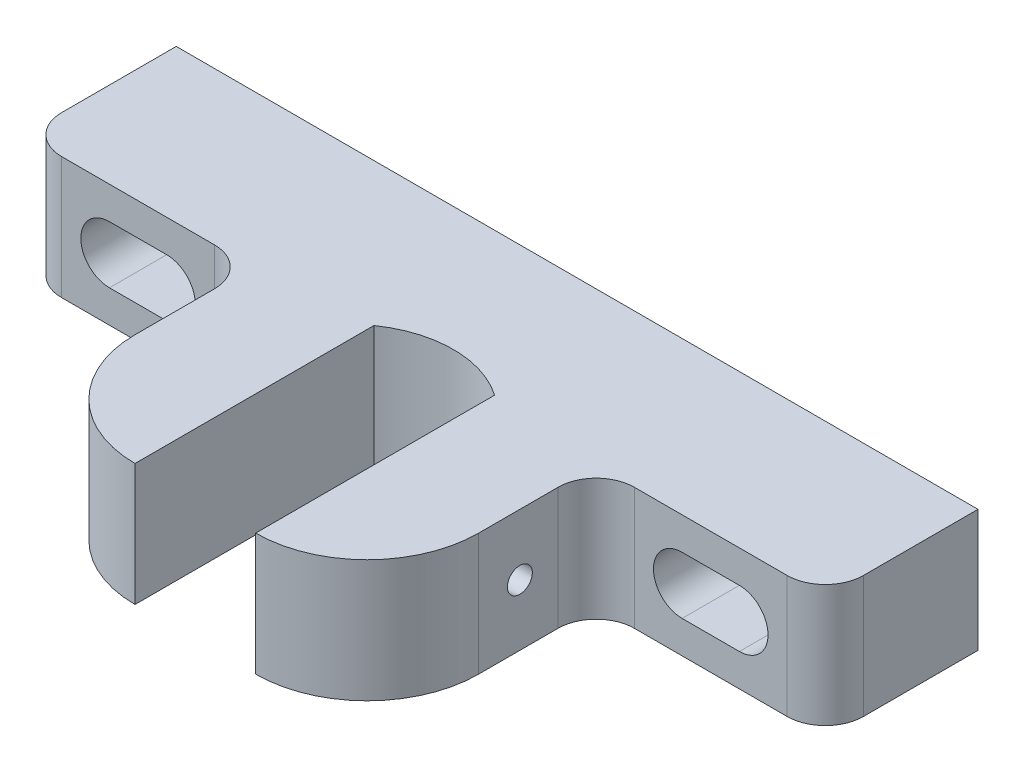
from build123d import *

# Parameters (mm, degrees)
SKETCH1_W          = 133.35
SKETCH1_H          = 20.32
EXTRUDE1_DEPTH     = 63.5
CUT_EXTRUDE1_DEPTH = 21.32
FILLET1_R          = 6.35
CUT_EXTRUDE2_DEPTH = 64.5
SKETCH6_R          = 2.07645
CUT_EXTRUDE5_DEPTH = 67.675


with BuildPart() as part:
    # Sketch1 → Extrude1 (new body)
    with BuildSketch(Plane.XY):
        with Locations((0, 14.12875)):
            Rectangle(SKETCH1_W, SKETCH1_H)
    extrude(amount=EXTRUDE1_DEPTH)

    # Sketch2 → Cut-Extrude1 (cut, through all)
    with BuildSketch(Plane.XZ.offset(-3.96875)):
        with BuildLine():
            Line((-10.033, 23.761628021), (-10.033, 63.5))
            ThreePointArc((-10.033, 63.5), (-23.144173937, 58.069173937), (-28.575, 44.958))
            Line((-28.575, 44.958), (-28.575, 31.75))
            ThreePointArc((-28.575, 31.75), (-30.434871939, 27.259871939), (-34.925, 25.4))
            Line((-34.925, 25.4), (-66.675, 25.4))
            Line((-66.675, 25.4), (-66.675, 63.5))
            Line((-66.675, 63.5), (-66.675, 81.695932909))
            Line((-66.675, 81.695932909), (66.675, 81.695932909))
            Line((66.675, 81.695932909), (66.675, 63.5))
            Line((66.675, 63.5), (66.675, 25.4))
            Line((66.675, 25.4), (34.925, 25.4))
            ThreePointArc((34.925, 25.4), (30.434871939, 27.259871939), (28.575, 31.75))
            Line((28.575, 31.75), (28.575, 44.958))
            ThreePointArc((28.575, 44.958), (23.144173937, 58.069173937), (10.033, 63.5))
            Line((10.033, 63.5), (10.033, 23.761628021))
            ThreePointArc((10.033, 23.761628021), (0, 20.6), (-10.033, 23.761628021))
        make_face()
    extrude(amount=-CUT_EXTRUDE1_DEPTH, mode=Mode.SUBTRACT)

    # Fillet1
    fillet1_edges = [part.edges().sort_by_distance(p)[0] for p in [
        (-66.675, 14.12875, 25.4),
        (66.675, 14.12875, 25.4),
    ]]
    fillet(fillet1_edges, radius=FILLET1_R)

    # Sketch3 → Cut-Extrude2 (cut, through all)
    with BuildSketch(Plane(origin=(0, 0, 0), x_dir=(-1, 0, 0), z_dir=(0, 0, -1))):
        with BuildLine():
            Line((-52.3875, 18.89125), (-42.8625, 18.89125))
            ThreePointArc((-42.8625, 18.89125), (-38.1, 14.12875), (-42.8625, 9.36625))
            Line((-42.8625, 9.36625), (-52.3875, 9.36625))
            ThreePointArc((-52.3875, 9.36625), (-57.15, 14.12875), (-52.3875, 18.89125))
        make_face()
        with BuildLine():
            Line((52.3875, 9.36625), (42.8625, 9.36625))
            ThreePointArc((42.8625, 9.36625), (38.1, 14.12875), (42.8625, 18.89125))
            Line((42.8625, 18.89125), (52.3875, 18.89125))
            ThreePointArc((52.3875, 18.89125), (57.15, 14.12875), (52.3875, 9.36625))
        make_face()
    extrude(amount=-CUT_EXTRUDE2_DEPTH, mode=Mode.SUBTRACT)

    # Sketch6 → Cut-Extrude5 (cut, through all)
    with BuildSketch(Plane(origin=(0, 0, 0), x_dir=(0, 0, -1), z_dir=(1, 0, 0))):
        with Locations((-38.1, 14.12875)):
            Circle(SKETCH6_R)
    extrude(amount=CUT_EXTRUDE5_DEPTH, mode=Mode.SUBTRACT)


solid = part.part
